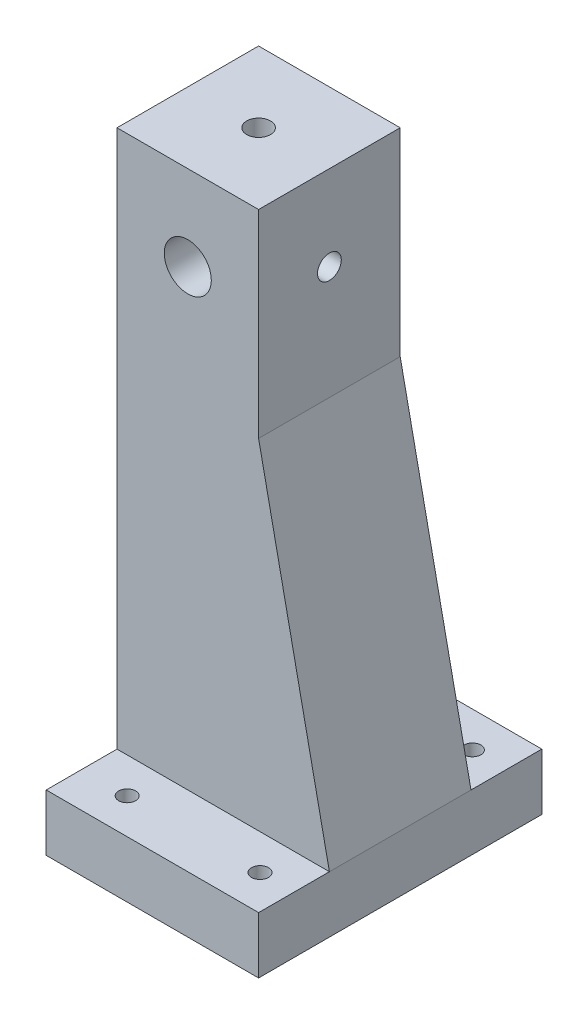
from build123d import *

# Parameters (mm, degrees)
CROQUIS1_W              = 50
CROQUIS1_H              = 25
SALIENTE_EXTRUIR1_DEPTH = 10
CROQUIS1_3_W            = 25
CROQUIS1_3_H            = 25
SALIENTE_EXTRUIR2_DEPTH = 105
CROQUIS2_R              = 4.15
CORTAR_EXTRUIR1_DEPTH   = 60
CROQUIS3_R              = 2.1
CORTAR_EXTRUIR2_DEPTH   = 10
CROQUIS1_4_W            = 50
CROQUIS1_4_H            = 12.5
SALIENTE_EXTRUIR3_DEPTH = 10
CROQUIS5_R              = 1.5
CORTAR_EXTRUIR4_DEPTH   = 10
CORTAR_EXTRUIR7_DEPTH   = 10
CROQUIS8_R              = 2.1
CORTAR_EXTRUIR9_DEPTH   = 15
CROQUIS9_R              = 1.5
CORTAR_EXTRUIR10_DEPTH  = 10
SALIENTE_EXTRUIR4_DEPTH = 12.5


with BuildPart() as part:
    # Croquis1 → Saliente-Extruir1 (new body)
    with BuildSketch(Plane(origin=(0, 0, 0), x_dir=(1, 0, 0), z_dir=(0, 1, 0))):
        Rectangle(CROQUIS1_W, CROQUIS1_H)
    extrude(amount=SALIENTE_EXTRUIR1_DEPTH)

    # Croquis1_3 → Saliente-Extruir2 (add)
    with BuildSketch(Plane(origin=(0, 0, 0), x_dir=(1, 0, 0), z_dir=(0, 1, 0))):
        Rectangle(CROQUIS1_3_W, CROQUIS1_3_H)
    extrude(amount=SALIENTE_EXTRUIR2_DEPTH)

    # Croquis2 → Cortar-Extruir1 (cut)
    with BuildSketch(Plane.XY.offset(12.5)):
        with Locations((0, 90)):
            Circle(CROQUIS2_R)
    extrude(amount=-CORTAR_EXTRUIR1_DEPTH, mode=Mode.SUBTRACT)

    # Croquis3 → Cortar-Extruir2 (cut)
    with BuildSketch(Plane(origin=(12.5, 0, 0), x_dir=(0, 0, -1), z_dir=(1, 0, 0))):
        with Locations((0, 90)):
            Circle(CROQUIS3_R)
    extrude(amount=-CORTAR_EXTRUIR2_DEPTH, mode=Mode.SUBTRACT)

    # Croquis1_4 → Saliente-Extruir3 (add)
    with BuildSketch(Plane(origin=(0, 0, 0), x_dir=(1, 0, 0), z_dir=(0, 1, 0))):
        with Locations((0, -18.75)):
            Rectangle(CROQUIS1_4_W, CROQUIS1_4_H)
        with Locations((0, 18.75)):
            Rectangle(CROQUIS1_4_W, CROQUIS1_4_H)
    extrude(amount=SALIENTE_EXTRUIR3_DEPTH)

    # Croquis5 → Cortar-Extruir4 (cut)
    with BuildSketch(Plane(origin=(0, 10, 0), x_dir=(1, 0, 0), z_dir=(0, 1, 0))):
        with Locations((-4.456486884, 18.75)):
            Circle(CROQUIS5_R)
        with Locations((-4.456486884, -18.75)):
            Circle(CROQUIS5_R)
    extrude(amount=-CORTAR_EXTRUIR4_DEPTH, mode=Mode.SUBTRACT)

    # Croquis6 → Cortar-Extruir7 (cut)
    with BuildSketch(Plane(origin=(0, 10, 0), x_dir=(1, 0, 0), z_dir=(0, 1, 0))):
        Polygon((-12.5, 25), (-12.5, 12.5), (-12.5, -12.5), (-12.5, -25), (-25, -25), (-25, 25), align=None)
    extrude(amount=-CORTAR_EXTRUIR7_DEPTH, mode=Mode.SUBTRACT)

    # Croquis8 → Cortar-Extruir9 (cut)
    with BuildSketch(Plane(origin=(0, 105, 0), x_dir=(1, 0, 0), z_dir=(0, 1, 0))):
        Circle(CROQUIS8_R)
    extrude(amount=-CORTAR_EXTRUIR9_DEPTH, mode=Mode.SUBTRACT)

    # Croquis9 → Cortar-Extruir10 (cut)
    with BuildSketch(Plane(origin=(0, 10, 0), x_dir=(1, 0, 0), z_dir=(0, 1, 0))):
        with Locations((19, -18.75)):
            Circle(CROQUIS9_R)
        with Locations((19, 18.75)):
            Circle(CROQUIS9_R)
    extrude(amount=-CORTAR_EXTRUIR10_DEPTH, mode=Mode.SUBTRACT)

    # Croquis10 → Saliente-Extruir4 (add, symmetric)
    with BuildSketch(Plane.XY):
        Polygon((12.5, 10), (25, 10), (12.5, 70), align=None)
    extrude(amount=SALIENTE_EXTRUIR4_DEPTH, both=True)


solid = part.part
